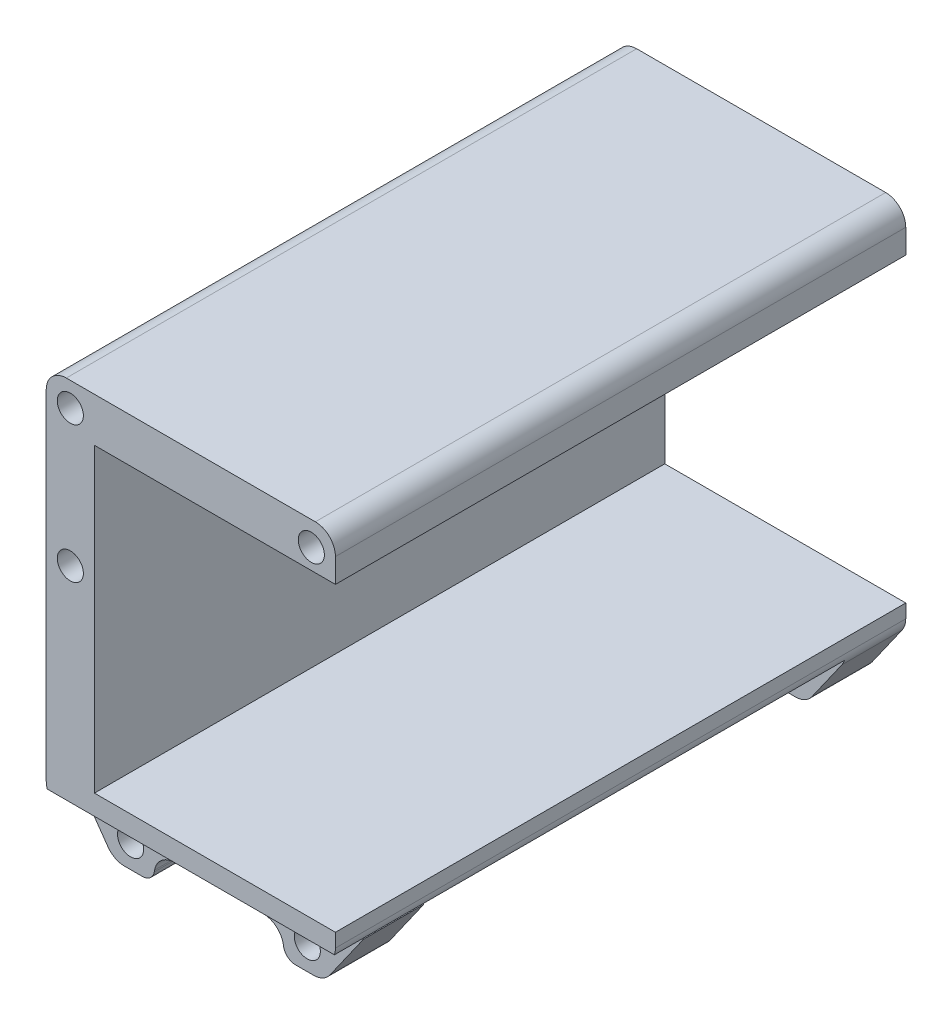
from build123d import *

# Parameters (mm, degrees)
SKETCH1_R           = 3.25
BOSS_EXTRUDE1_DEPTH = 142
SKETCH2_W           = 127
SKETCH2_H           = 26.313308587
CUT_EXTRUDE1_DEPTH  = 73
FILLET1_R           = 5
SKETCH3_R           = 3.25
BOSS_EXTRUDE2_DEPTH = 15


with BuildPart() as part:
    # Sketch1 → Boss-Extrude1 (new body)
    with BuildSketch(Plane.XY):
        with BuildLine():
            Line((36, 88.659292886), (36, 99.659292886))
            Line((36, 99.659292886), (-31, 99.659292886))
            ThreePointArc((-31, 99.659292886), (-34.535533906, 98.194826792), (-36, 94.659292886))
            Line((-36, 94.659292886), (-36, 10.242951409))
            ThreePointArc((-36, 10.242951409), (-35.766621895, 8.733211131), (-35.088273717, 7.364406982))
            Line((-35.088273717, 7.364406982), (-27.636343301, -3.219251541))
            ThreePointArc((-27.636343301, -3.219251541), (-25.851032661, -4.778765368), (-23.548069585, -5.340707114))
            Line((-23.548069585, -5.340707114), (-19.04842059, -5.340707114))
            ThreePointArc((-19.04842059, -5.340707114), (-17.127708267, -4.64523834), (-16.09752624, -2.881283229))
            Line((-16.09752624, -2.881283229), (-16.016640938, -2.439746922))
            ThreePointArc((-16.016640938, -2.439746922), (-14.299670893, 0.500178263), (-11.098483688, 1.659292886))
            Line((-11.098483688, 1.659292886), (11.098483688, 1.659292886))
            ThreePointArc((11.098483688, 1.659292886), (14.299670893, 0.500178263), (16.016640938, -2.439746922))
            Line((16.016640938, -2.439746922), (16.09752624, -2.881283229))
            ThreePointArc((16.09752624, -2.881283229), (17.127708267, -4.64523834), (19.04842059, -5.340707114))
            Line((19.04842059, -5.340707114), (23.548069585, -5.340707114))
            ThreePointArc((23.548069585, -5.340707114), (25.851032661, -4.778765368), (27.636343301, -3.219251541))
            Line((27.636343301, -3.219251541), (35.088273717, 7.364406982))
            ThreePointArc((35.088273717, 7.364406982), (35.766621895, 8.733211131), (36, 10.242951409))
            Line((36, 10.242951409), (36, 13.659292886))
            Line((36, 13.659292886), (-24, 13.659292886))
            Line((-24, 13.659292886), (-24, 88.659292886))
            Line((-24, 88.659292886), (36, 88.659292886))
        make_face()
        with Locations((30, 93.659292886)):
            Circle(SKETCH1_R, mode=Mode.SUBTRACT)
        with Locations((-30, 93.659292886)):
            Circle(SKETCH1_R, mode=Mode.SUBTRACT)
        with Locations((-30, 59.659292886)):
            Circle(SKETCH1_R, mode=Mode.SUBTRACT)
    extrude(amount=BOSS_EXTRUDE1_DEPTH)

    # Sketch2 → Cut-Extrude1 (cut, through all)
    with BuildSketch(Plane.ZY.offset(36)):
        with Locations((78.5, -4.497361408)):
            Rectangle(SKETCH2_W, SKETCH2_H)
    extrude(amount=-CUT_EXTRUDE1_DEPTH, mode=Mode.SUBTRACT)

    # Fillet1
    fillet1_edges = [part.edges().sort_by_distance(p)[0] for p in [
        (36, 99.659292886, 71),
    ]]
    fillet(fillet1_edges, radius=FILLET1_R)

    # Sketch3 → Boss-Extrude2 (add)
    with BuildSketch(Plane.XY.offset(120)):
        with BuildLine():
            Line((-36, 8.659292886), (-27.636343301, -3.219251541))
            ThreePointArc((-27.636343301, -3.219251541), (-25.851032661, -4.778765368), (-23.548069585, -5.340707114))
            Line((-23.548069585, -5.340707114), (-19.04842059, -5.340707114))
            ThreePointArc((-19.04842059, -5.340707114), (-17.127708267, -4.64523834), (-16.09752624, -2.881283229))
            Line((-16.09752624, -2.881283229), (-16.016640938, -2.439746922))
            ThreePointArc((-16.016640938, -2.439746922), (-14.299670893, 0.500178263), (-11.098483688, 1.659292886))
            Line((-11.098483688, 1.659292886), (11.098483688, 1.659292886))
            ThreePointArc((11.098483688, 1.659292886), (14.299670893, 0.500178263), (16.016640938, -2.439746922))
            Line((16.016640938, -2.439746922), (16.09752624, -2.881283229))
            ThreePointArc((16.09752624, -2.881283229), (17.127708267, -4.64523834), (19.04842059, -5.340707114))
            Line((19.04842059, -5.340707114), (23.548069585, -5.340707114))
            ThreePointArc((23.548069585, -5.340707114), (25.851032661, -4.778765368), (27.636343301, -3.219251541))
            Line((27.636343301, -3.219251541), (36, 8.659292886))
            Line((36, 8.659292886), (-36, 8.659292886))
        make_face()
        with Locations((-22, 0.659292886)):
            Circle(SKETCH3_R, mode=Mode.SUBTRACT)
        with Locations((22, 0.659292886)):
            Circle(SKETCH3_R, mode=Mode.SUBTRACT)
    extrude(amount=BOSS_EXTRUDE2_DEPTH)


solid = part.part
